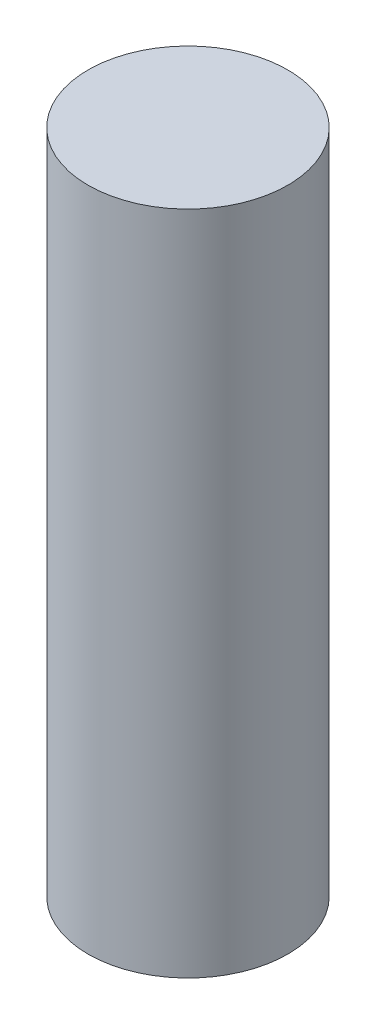
from build123d import *

# Parameters (mm, degrees)
SKETCH1_R           = 7.5
BOSS_EXTRUDE1_DEPTH = 50


with BuildPart() as part:
    # Sketch1 → Boss-Extrude1 (new body)
    with BuildSketch(Plane(origin=(0, 0, 0), x_dir=(1, 0, 0), z_dir=(0, 1, 0))):
        Circle(SKETCH1_R)
    extrude(amount=BOSS_EXTRUDE1_DEPTH)


solid = part.part
